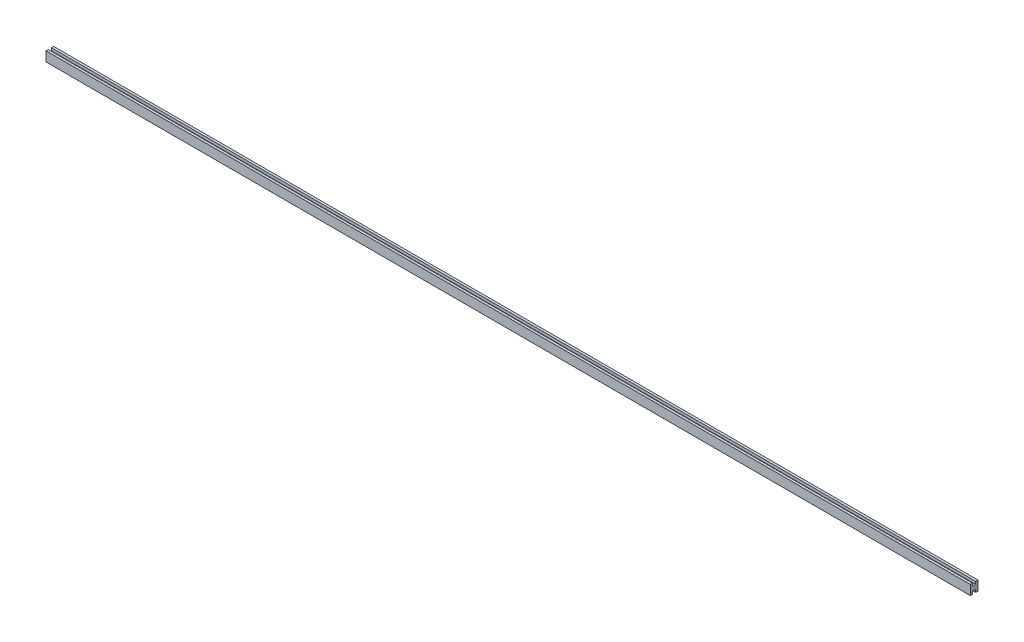
from build123d import *

# Parameters (mm, degrees)
BOSS_EXTRUDE1_DEPTH = 3048


with BuildPart() as part:
    # Sketch1 → Boss-Extrude1 (new body)
    with BuildSketch(Plane(origin=(0, 0, 0), x_dir=(0, 0, -1), z_dir=(1, 0, 0))):
        Polygon((5.08, -15.875), (12.7, -15.875), (12.7, 15.875), (5.08, 15.875), (5.08, 6.985), (-5.08, 6.985), (-5.08, 15.875), (-12.7, 15.875), (-12.7, -15.875), (-5.08, -15.875), (-5.08, -6.985), (5.08, -6.985), align=None)
    extrude(amount=BOSS_EXTRUDE1_DEPTH)


solid = part.part
